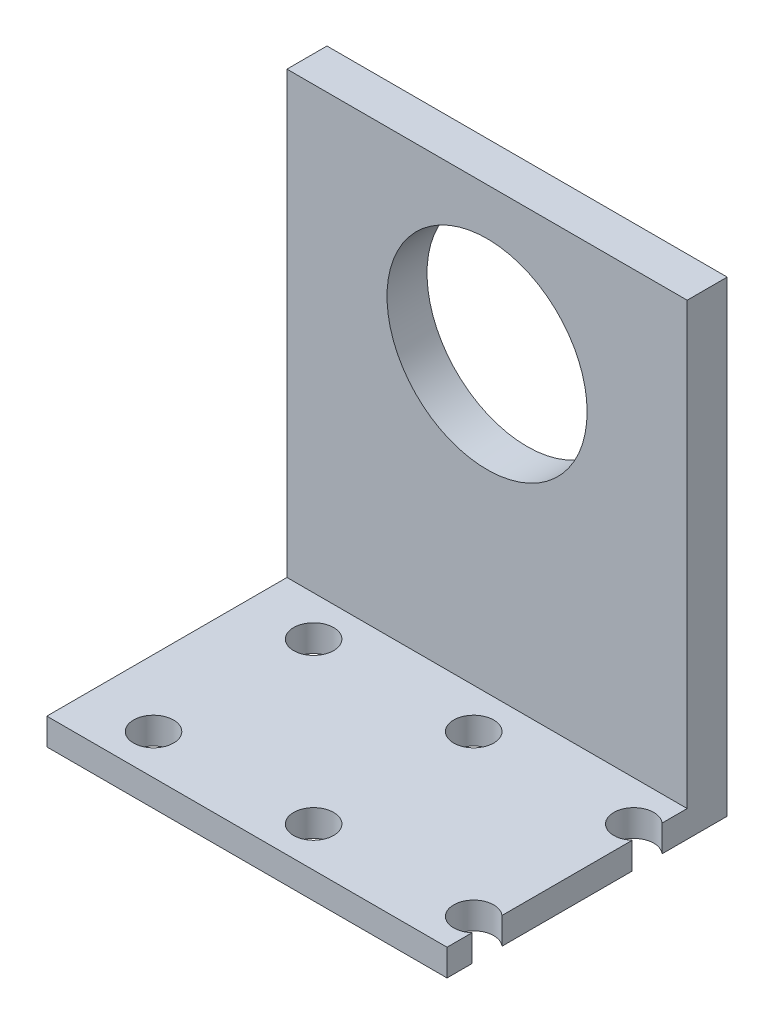
from build123d import *

# Parameters (mm, degrees)
BOSS_EXTRUDE1_DEPTH = 30
SKETCH2_R           = 7.5
CUT_EXTRUDE1_DEPTH  = 30
SKETCH5_R           = 1.5
CUT_EXTRUDE2_DEPTH  = 30


with BuildPart() as part:
    # Sketch1 → Boss-Extrude1 (new body)
    with BuildSketch(Plane(origin=(0, 0, 0), x_dir=(0, 0, -1), z_dir=(1, 0, 0))):
        Polygon((0, 0), (18, 0), (18, 33), (21, 33), (21, -2), (0, -2), align=None)
    extrude(amount=BOSS_EXTRUDE1_DEPTH)

    # Sketch2 → Cut-Extrude1 (cut)
    with BuildSketch(Plane.XY.offset(-18)):
        with Locations((15, 22)):
            Circle(SKETCH2_R)
    extrude(amount=-CUT_EXTRUDE1_DEPTH, mode=Mode.SUBTRACT)

    # Sketch5 → Cut-Extrude2 (cut)
    with BuildSketch(Plane(origin=(0, 0, 0), x_dir=(1, 0, 0), z_dir=(0, 1, 0))):
        with Locations((5, 3)):
            Circle(SKETCH5_R)
        with Locations((17, 3)):
            Circle(SKETCH5_R)
        with Locations((29, 3)):
            Circle(SKETCH5_R)
        with Locations((17, 15)):
            Circle(SKETCH5_R)
        with Locations((29, 15)):
            Circle(SKETCH5_R)
        with Locations((5, 15)):
            Circle(SKETCH5_R)
    extrude(amount=-CUT_EXTRUDE2_DEPTH, mode=Mode.SUBTRACT)


solid = part.part
